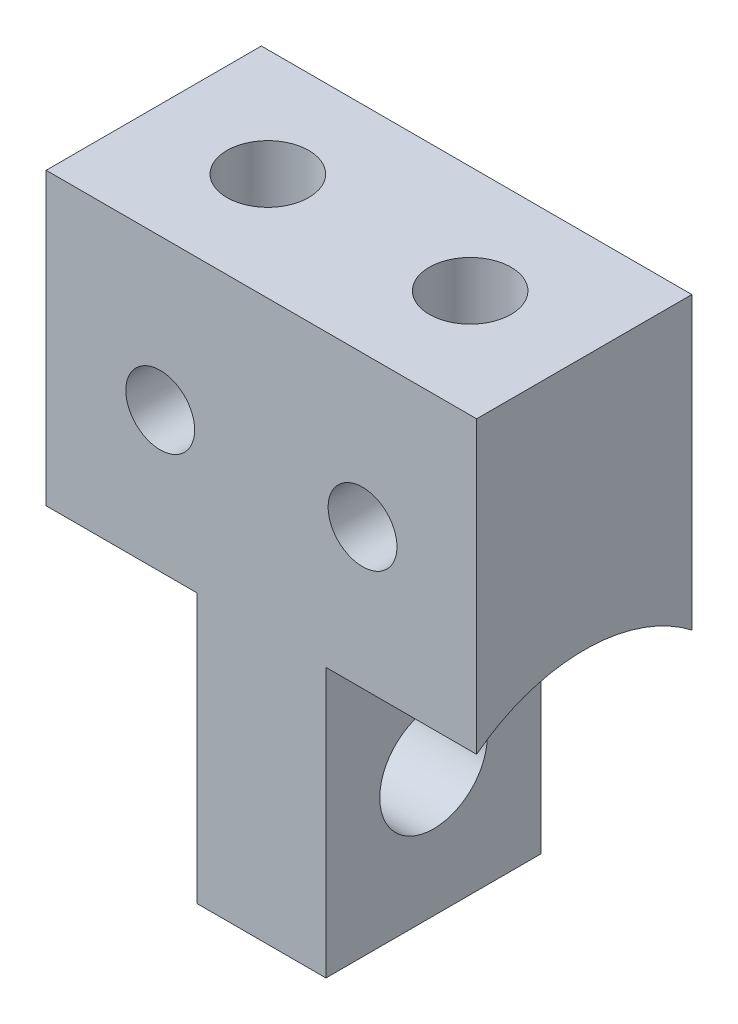
from build123d import *

# Parameters (mm, degrees)
SKETCH1_W           = 10
SKETCH1_H           = 13
SKETCH1_R           = 0.8
BOSS_EXTRUDE1_DEPTH = 5
CUT_EXTRUDE2_DEPTH  = 3.5
SKETCH4_R           = 1.25
CUT_EXTRUDE3_DEPTH  = 7.5
SKETCH5_R           = 0.95
CUT_EXTRUDE4_DEPTH  = 3


with BuildPart() as part:
    # Sketch1 → Boss-Extrude1 (new body)
    with BuildSketch(Plane.XY):
        Rectangle(SKETCH1_W, SKETCH1_H)
        with Locations((-2.35, 3)):
            Circle(SKETCH1_R, mode=Mode.SUBTRACT)
        with Locations((2.35, 3)):
            Circle(SKETCH1_R, mode=Mode.SUBTRACT)
    extrude(amount=BOSS_EXTRUDE1_DEPTH)

    # Sketch3 → Cut-Extrude2 (cut)
    with BuildSketch(Plane.ZY.offset(5)):
        with BuildLine():
            Line((-1.6, -3.5), (-1.6, -7.6))
            Line((-1.6, -7.6), (6.6, -7.6))
            Line((6.6, -7.6), (6.6, -3.5))
            ThreePointArc((6.6, -3.5), (2.5, 0.6), (-1.6, -3.5))
        make_face()
    cut_extrude2 = extrude(amount=-CUT_EXTRUDE2_DEPTH, mode=Mode.SUBTRACT)

    # Mirror1: Cut-Extrude2 across plane
    add(cut_extrude2.mirror(Plane(origin=(0, 0, 0), x_dir=(0, 0, 1), z_dir=(1, 0, 0))), mode=Mode.SUBTRACT)

    # Sketch4 → Cut-Extrude3 (cut, through all)
    with BuildSketch(Plane.ZY.offset(1.5)):
        with Locations((2.5, -3.5)):
            Circle(SKETCH4_R)
    extrude(amount=-CUT_EXTRUDE3_DEPTH, mode=Mode.SUBTRACT)

    # Sketch5 → Cut-Extrude4 (cut)
    with BuildSketch(Plane(origin=(0, 6.5, 0), x_dir=(1, 0, 0), z_dir=(0, 1, 0))):
        with Locations((-2.35, -2.5)):
            Circle(SKETCH5_R)
        with Locations((2.35, -2.5)):
            Circle(SKETCH5_R)
    extrude(amount=-CUT_EXTRUDE4_DEPTH, mode=Mode.SUBTRACT)


solid = part.part
